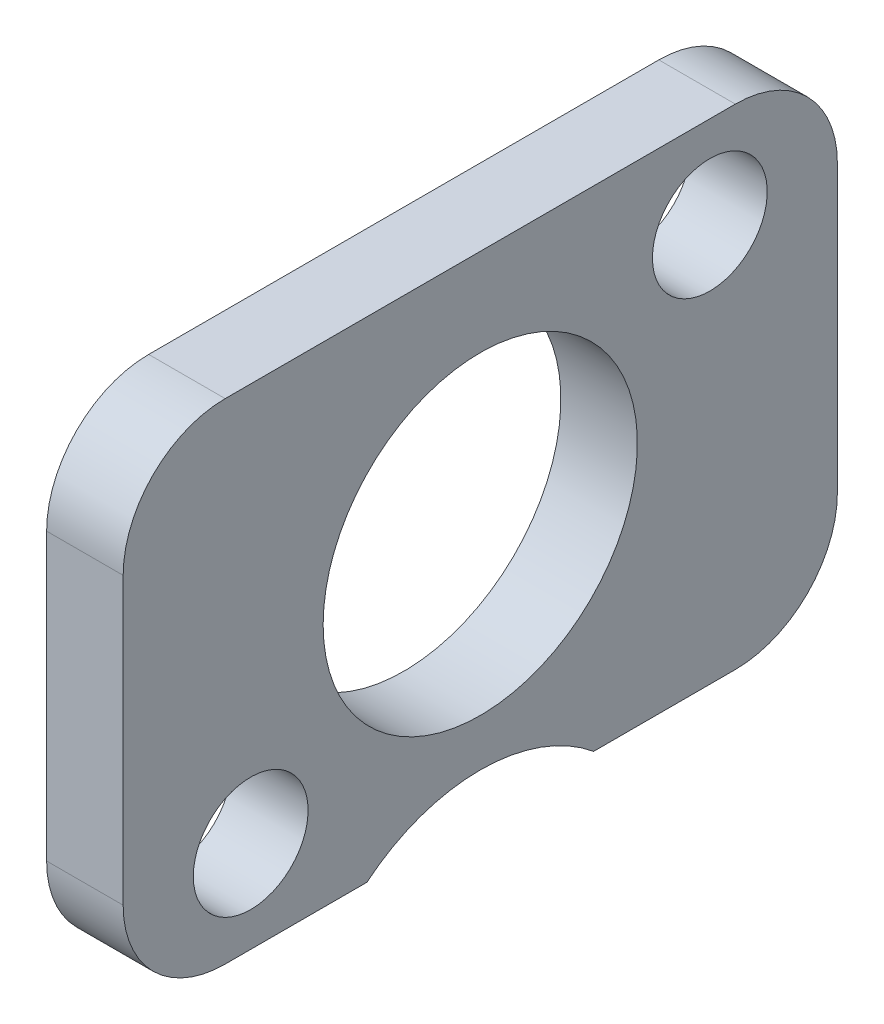
from build123d import *

# Parameters (mm, degrees)
SKETCH2_R      = 4.8895
SKETCH2_R_2    = 1.7859375
EXTRUDE1_DEPTH = 2.38125


with BuildPart() as part:
    # Sketch2 → Extrude1 (new body)
    with BuildSketch(Plane.ZY):
        with BuildLine():
            Line((7.9375, -7.62), (3.527817924, -7.62))
            ThreePointArc((3.527817924, -7.62), (0, -6.35635), (-3.527817924, -7.62))
            Line((-3.527817924, -7.62), (-7.9375, -7.62))
            ThreePointArc((-7.9375, -7.62), (-10.18256403, -6.69006403), (-11.1125, -4.445))
            Line((-11.1125, -4.445), (-11.1125, 4.445))
            ThreePointArc((-11.1125, 4.445), (-10.18256403, 6.69006403), (-7.9375, 7.62))
            Line((-7.9375, 7.62), (7.9375, 7.62))
            ThreePointArc((7.9375, 7.62), (10.18256403, 6.69006403), (11.1125, 4.445))
            Line((11.1125, 4.445), (11.1125, -4.445))
            ThreePointArc((11.1125, -4.445), (10.18256403, -6.69006403), (7.9375, -7.62))
        make_face()
        Circle(SKETCH2_R, mode=Mode.SUBTRACT)
        with Locations((-7.14375, 4.7625)):
            Circle(SKETCH2_R_2, mode=Mode.SUBTRACT)
        with Locations((7.14375, -4.7625)):
            Circle(SKETCH2_R_2, mode=Mode.SUBTRACT)
    extrude(amount=-EXTRUDE1_DEPTH)


solid = part.part
